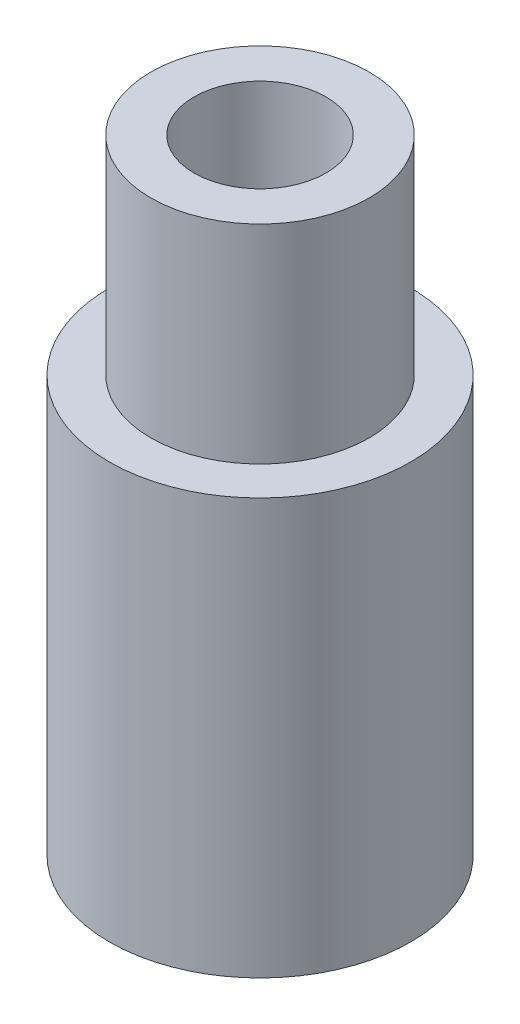
from build123d import *

# Parameters (mm, degrees)
SKETCH1_R           = 7.25
SKETCH1_R_2         = 3.175
BOSS_EXTRUDE1_DEPTH = 30
SKETCH2_OUTSIDE_W   = 23.768
SKETCH2_OUTSIDE_H   = 23.768
SKETCH2_OUTSIDE_R   = 5.25
CUT_EXTRUDE1_DEPTH  = 10
SKETCH3_R           = 5.25
CUT_EXTRUDE2_DEPTH  = 10


with BuildPart() as part:
    # Sketch1 → Boss-Extrude1 (new body)
    with BuildSketch(Plane(origin=(0, 0, 0), x_dir=(1, 0, 0), z_dir=(0, 1, 0))):
        Circle(SKETCH1_R)
        Circle(SKETCH1_R_2, mode=Mode.SUBTRACT)
    extrude(amount=BOSS_EXTRUDE1_DEPTH)

    # Sketch2 outside → Cut-Extrude1 (cut)
    with BuildSketch(Plane(origin=(0, 30, 0), x_dir=(1, 0, 0), z_dir=(0, 1, 0))):
        Rectangle(SKETCH2_OUTSIDE_W, SKETCH2_OUTSIDE_H)
        Circle(SKETCH2_OUTSIDE_R, mode=Mode.SUBTRACT)
    extrude(amount=-CUT_EXTRUDE1_DEPTH, mode=Mode.SUBTRACT)

    # Sketch3 → Cut-Extrude2 (cut)
    with BuildSketch(Plane.XZ):
        Circle(SKETCH3_R)
    extrude(amount=-CUT_EXTRUDE2_DEPTH, mode=Mode.SUBTRACT)


solid = part.part
